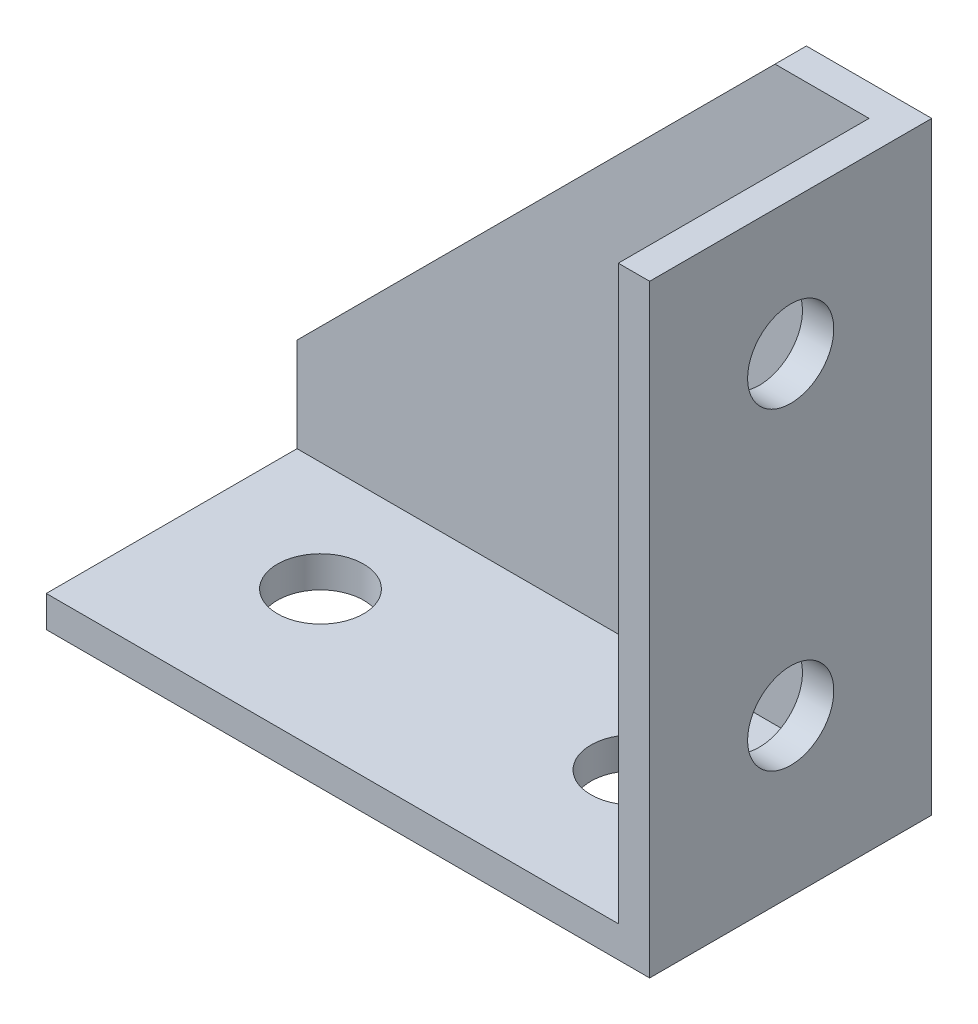
from build123d import *

# Parameters (mm, degrees)
EXTRUDE_1_DEPTH     = 18
CUT_EXTRUDE_1_DEPTH = 16
HOLE_WIZARD_M51_D   = 5.5
HOLE_WIZARD_M52_D   = 5.5


with BuildPart() as part:
    # Эскиз1 → Бобышка-Вытянуть1 (new body)
    with BuildSketch(Plane.XY):
        Polygon((0, 0), (0, 8), (30.5, 38.5), (38.5, 38.5), (38.5, 0), align=None)
    extrude(amount=EXTRUDE_1_DEPTH)

    # Эскиз2 → Вырез-Вытянуть1 (cut)
    with BuildSketch(Plane.XY.offset(18)):
        Polygon((0, 2), (36.5, 2), (36.5, 38.5), (30.5, 38.5), (0, 8), align=None)
    extrude(amount=-CUT_EXTRUDE_1_DEPTH, mode=Mode.SUBTRACT)

    # Отверстие с зазором M51 (through all)
    with Locations(Plane(origin=(0, 2, 0), x_dir=(1, 0, 0), z_dir=(0, 1, 0))):
        with Locations((8.5, -9), (28.5, -9)):
            Hole(HOLE_WIZARD_M51_D / 2)

    # Отверстие с зазором M52 (through all)
    with Locations(Plane.ZY.offset(-36.5)):
        with Locations((9, 10), (9, 30)):
            Hole(HOLE_WIZARD_M52_D / 2)


solid = part.part
